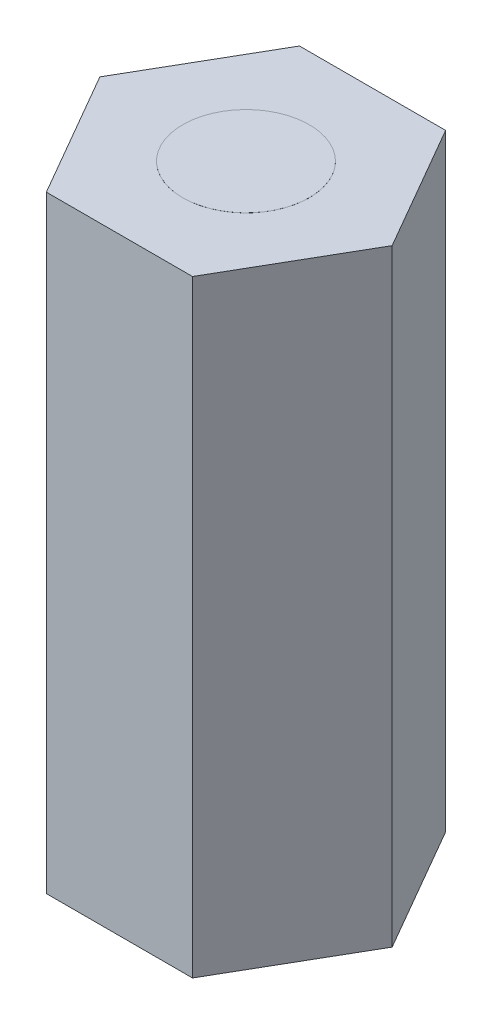
from build123d import *

# Parameters (mm, degrees)
BOSS_EXTRUDE1_DEPTH = 12
SKETCH2_R           = 1.25
BOSS_EXTRUDE2_DEPTH = 0.001


with BuildPart() as part:
    # Sketch1 → Boss-Extrude1 (new body)
    with BuildSketch(Plane(origin=(0, 0, 0), x_dir=(1, 0, 0), z_dir=(0, 1, 0))):
        Polygon((-2.886751346, 0), (-1.443375673, -2.5), (1.443375673, -2.5), (2.886751346, 0), (1.443375673, 2.5), (-1.443375673, 2.5), align=None)
    extrude(amount=BOSS_EXTRUDE1_DEPTH)

    # Sketch2 → Boss-Extrude2 (add)
    with BuildSketch(Plane(origin=(0, 12, 0), x_dir=(1, 0, 0), z_dir=(0, 1, 0))):
        Circle(SKETCH2_R)
    extrude(amount=BOSS_EXTRUDE2_DEPTH)


solid = part.part
